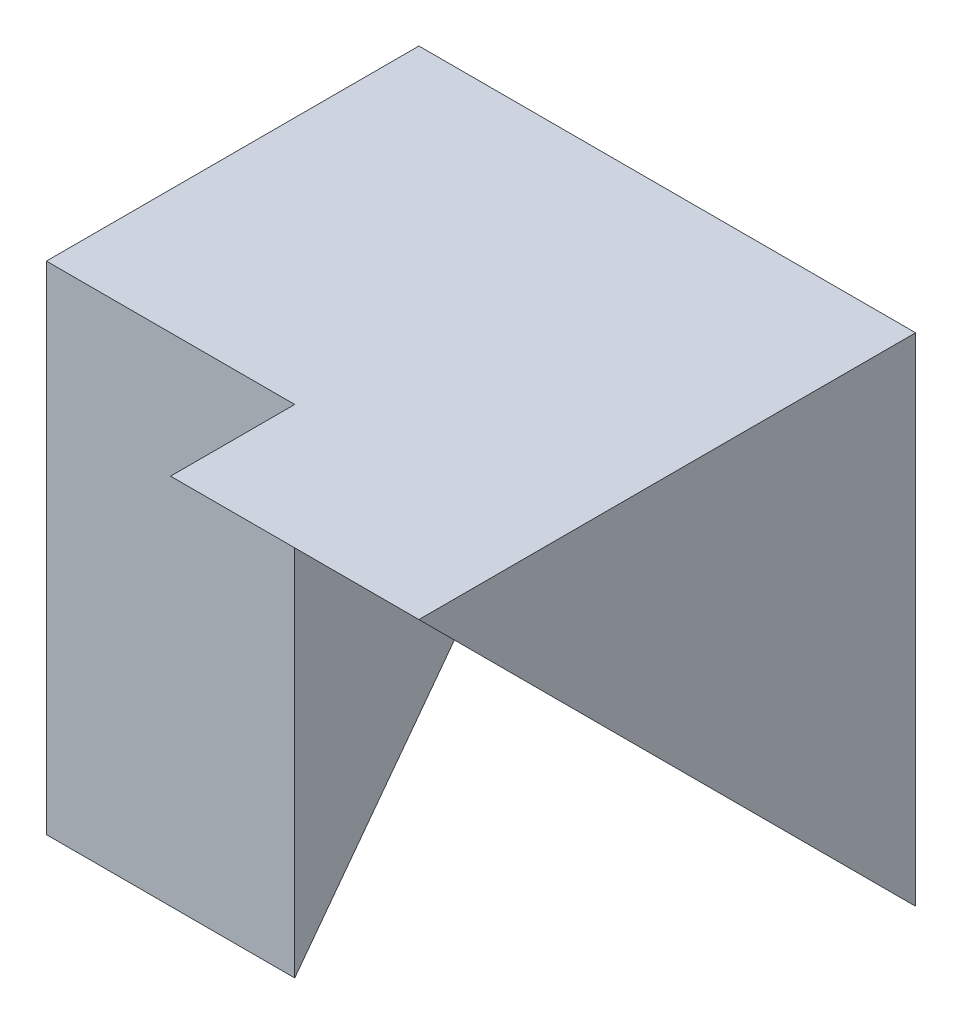
from build123d import *

# Parameters (mm, degrees)
SKETCH1_W           = 4
SKETCH1_H           = 4
BOSS_EXTRUDE1_DEPTH = 2
SKETCH2_W           = 3
SKETCH2_H           = 4
BOSS_EXTRUDE2_DEPTH = 2
CUT_EXTRUDE1_DEPTH  = 2
CUT_EXTRUDE2_DEPTH  = 2


with BuildPart() as part:
    # Sketch1 → Boss-Extrude1 (new body)
    with BuildSketch(Plane(origin=(0, 0, 0), x_dir=(0, 0, -1), z_dir=(1, 0, 0))):
        with Locations((2, 2)):
            Rectangle(SKETCH1_W, SKETCH1_H)
    extrude(amount=BOSS_EXTRUDE1_DEPTH)

    # Sketch2 → Boss-Extrude2 (add)
    with BuildSketch(Plane.ZY):
        with Locations((-2.5, 2)):
            Rectangle(SKETCH2_W, SKETCH2_H)
    extrude(amount=BOSS_EXTRUDE2_DEPTH)

    # Sketch3 → Cut-Extrude1 (cut)
    with BuildSketch(Plane(origin=(2, 0, 0), x_dir=(0, 0, -1), z_dir=(1, 0, 0))):
        Polygon((4, 0), (0, 4), (0, 0), align=None)
    extrude(amount=-CUT_EXTRUDE1_DEPTH, mode=Mode.SUBTRACT)

    # Sketch4 → Cut-Extrude2 (cut)
    with BuildSketch(Plane.ZY.offset(2)):
        Polygon((-1, 0), (-4, 4), (-4, 0), align=None)
    extrude(amount=-CUT_EXTRUDE2_DEPTH, mode=Mode.SUBTRACT)


solid = part.part
